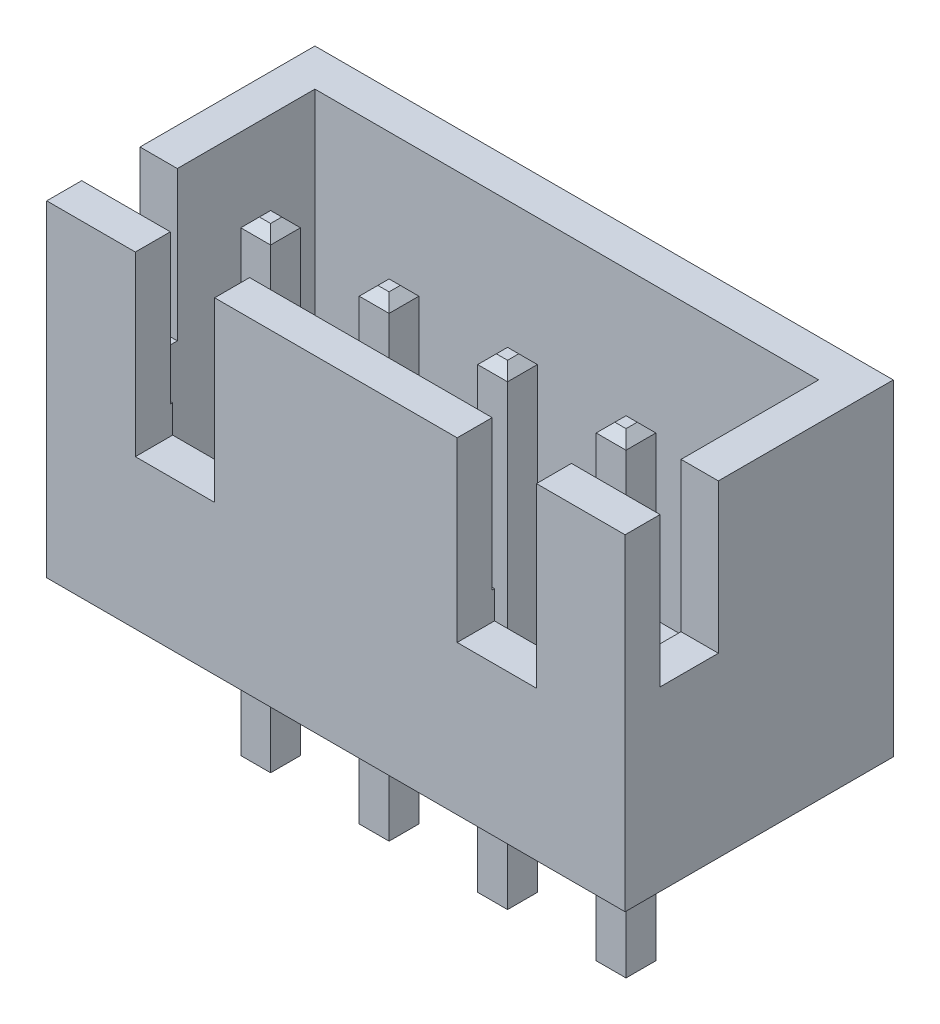
from build123d import *

# Parameters (mm, degrees)
SKETCH1_W                = 12.4
SKETCH1_H                = 5.75
BOSS_EXTRUDE1_DEPTH      = 7
SHELL1_T                 = -0.8
SKETCH2_W                = 1.25
SKETCH2_H                = 3.2
CUT_EXTRUDE1_DEPTH       = 13.4
CUT_EXTRUDE2_REACH       = 7.75
SKETCH3_W                = 1.7
SKETCH3_H                = 3.8
SKETCH4_W                = 0.64
SKETCH4_H                = 0.64
BOSS_EXTRUDE2_DEPTH      = 3.45
BOSS_EXTRUDE2_DEPTH_BACK = 6.75
CHAMFER1_SIZE            = 0.2


with BuildPart() as part:
    # Sketch1 → Boss-Extrude1 (new body)
    with BuildSketch(Plane(origin=(0, 0, 0), x_dir=(1, 0, 0), z_dir=(0, 1, 0))):
        Rectangle(SKETCH1_W, SKETCH1_H)
    extrude(amount=BOSS_EXTRUDE1_DEPTH)

    # Shell1
    shell1_openings = [part.faces().sort_by_distance(p)[0] for p in [
        (0, 7, 0),
    ]]
    offset(amount=SHELL1_T, openings=shell1_openings, kind=Kind.INTERSECTION)

    # Sketch2 → Cut-Extrude1 (cut, through all)
    with BuildSketch(Plane(origin=(6.2, 0, 0), x_dir=(0, 0, -1), z_dir=(1, 0, 0))):
        with Locations((-1.5, 5.4)):
            Rectangle(SKETCH2_W, SKETCH2_H)
    extrude(amount=-CUT_EXTRUDE1_DEPTH, mode=Mode.SUBTRACT)

    # Sketch3 → Cut-Extrude2 (cut, up to next)
    with BuildSketch(Plane.XY.offset(2.875), mode=Mode.PRIVATE) as cut_extrude2_sk1:
        with Locations((-3.45, 5.1)):
            Rectangle(SKETCH3_W, SKETCH3_H)
    cut_extrude2_tool1 = extrude(cut_extrude2_sk1.sketch, amount=-CUT_EXTRUDE2_REACH, mode=Mode.PRIVATE) & part.part
    add(cut_extrude2_tool1.solids().sort_by_distance((-3.45, 5.1, 2.875))[0], mode=Mode.SUBTRACT)
    # Sketch3 → Cut-Extrude2 (cut, up to next)
    with BuildSketch(Plane.XY.offset(2.875), mode=Mode.PRIVATE) as cut_extrude2_sk2:
        with Locations((3.45, 5.1)):
            Rectangle(SKETCH3_W, SKETCH3_H)
    cut_extrude2_tool2 = extrude(cut_extrude2_sk2.sketch, amount=-CUT_EXTRUDE2_REACH, mode=Mode.PRIVATE) & part.part
    add(cut_extrude2_tool2.solids().sort_by_distance((3.45, 5.1, 2.875))[0], mode=Mode.SUBTRACT)

    # Sketch4 → Boss-Extrude2 (add, two sides)
    with BuildSketch(Plane.XZ) as boss_extrude2_sk:
        with Locations((-3.75, 0.525)):
            Rectangle(SKETCH4_W, SKETCH4_H)
        with Locations((-1.21, 0.525)):
            Rectangle(SKETCH4_W, SKETCH4_H)
        with Locations((1.33, 0.525)):
            Rectangle(SKETCH4_W, SKETCH4_H)
        with Locations((3.87, 0.525)):
            Rectangle(SKETCH4_W, SKETCH4_H)
    extrude(amount=BOSS_EXTRUDE2_DEPTH)
    extrude(boss_extrude2_sk.sketch, amount=-BOSS_EXTRUDE2_DEPTH_BACK)

    # Chamfer1
    chamfer1_edges = [part.edges().sort_by_distance(p)[0] for p in [
        (-1.21, 6.75, 0.205),
        (-1.53, 6.75, 0.525),
        (-1.21, 6.75, 0.845),
        (-0.89, 6.75, 0.525),
        (-1.21, -3.45, 0.205),
        (-0.89, -3.45, 0.525),
        (-1.21, -3.45, 0.845),
        (-1.53, -3.45, 0.525),
        (1.33, 6.75, 0.205),
        (1.01, 6.75, 0.525),
        (1.33, 6.75, 0.845),
        (1.65, 6.75, 0.525),
        (1.33, -3.45, 0.205),
        (1.65, -3.45, 0.525),
        (1.33, -3.45, 0.845),
        (1.01, -3.45, 0.525),
        (3.87, 6.75, 0.205),
        (3.55, 6.75, 0.525),
        (3.87, 6.75, 0.845),
        (4.19, 6.75, 0.525),
        (3.87, -3.45, 0.205),
        (4.19, -3.45, 0.525),
        (3.87, -3.45, 0.845),
        (3.55, -3.45, 0.525),
        (-3.43, 6.75, 0.525),
        (-3.75, 6.75, 0.205),
        (-4.07, 6.75, 0.525),
        (-3.75, 6.75, 0.845),
        (-3.43, -3.45, 0.525),
        (-3.75, -3.45, 0.845),
        (-4.07, -3.45, 0.525),
        (-3.75, -3.45, 0.205),
    ]]
    chamfer(chamfer1_edges, length=CHAMFER1_SIZE)


solid = part.part
